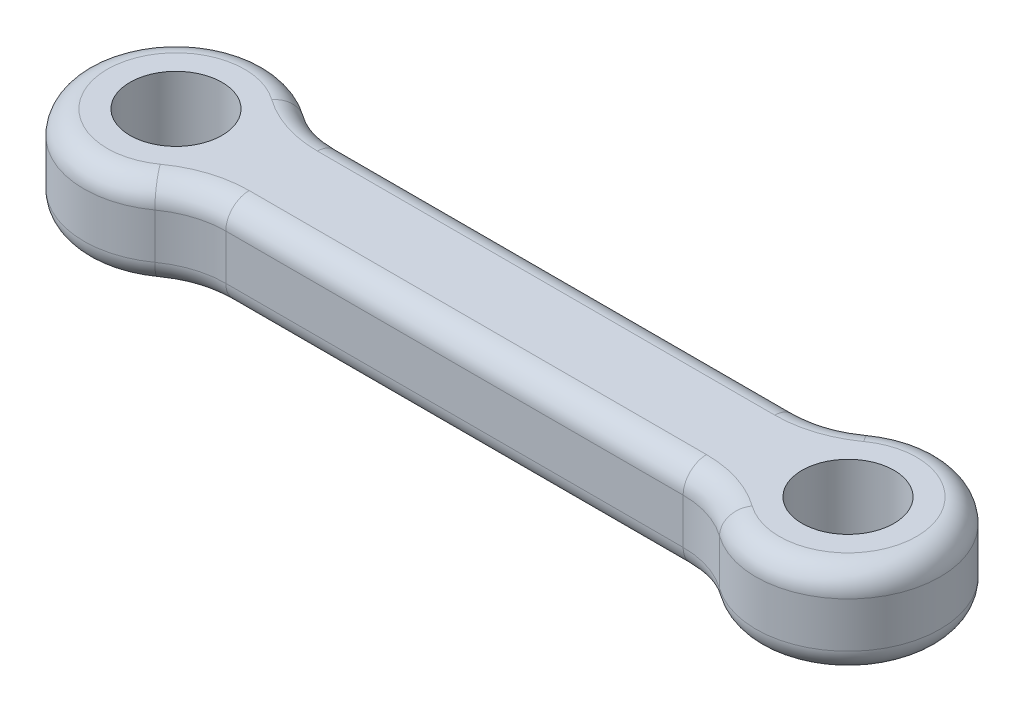
from build123d import *

# Parameters (mm, degrees)
SKETCH1_R           = 5
BOSS_EXTRUDE1_DEPTH = 10
FILLET1_R           = 2.54
SCALE1_SCALE        = 0.66


with BuildPart() as part:
    # Sketch1 → Boss-Extrude1 (new body)
    with BuildSketch(Plane(origin=(0, 0, 0), x_dir=(1, 0, 0), z_dir=(0, 1, 0))):
        with BuildLine():
            Line((-6.590776184, -6.25), (43.090776184, -6.25))
            ThreePointArc((43.090776184, -6.25), (46.152638362, -6.730283618), (48.920388092, -8.125))
            ThreePointArc((48.920388092, -8.125), (64.75, 0), (48.920388092, 8.125))
            ThreePointArc((48.920388092, 8.125), (46.152638362, 6.730283618), (43.090776184, 6.25))
            Line((43.090776184, 6.25), (-6.590776184, 6.25))
            ThreePointArc((-6.590776184, 6.25), (-9.652638362, 6.730283618), (-12.420388092, 8.125))
            ThreePointArc((-12.420388092, 8.125), (-28.25, 0), (-12.420388092, -8.125))
            ThreePointArc((-12.420388092, -8.125), (-9.652638362, -6.730283618), (-6.590776184, -6.25))
        make_face()
        with Locations((-18.25, 0)):
            Circle(SKETCH1_R, mode=Mode.SUBTRACT)
        with Locations((54.75, 0)):
            Circle(SKETCH1_R, mode=Mode.SUBTRACT)
    extrude(amount=BOSS_EXTRUDE1_DEPTH)

    # Fillet1
    fillet1_edges = [part.edges().sort_by_distance(p)[0] for p in [
        (-9.652638362, 10, 6.730283618),
        (-28.25, 0, 0),
        (-9.652638362, 0, -6.730283618),
        (18.25, 10, 6.25),
        (46.152638362, 10, 6.730283618),
        (64.75, 10, 0),
        (46.152638362, 10, -6.730283618),
        (18.25, 10, -6.25),
        (-9.652638362, 10, -6.730283618),
        (-28.25, 10, 0),
        (18.25, 0, -6.25),
        (46.152638362, 0, -6.730283618),
        (64.75, 0, 0),
        (46.152638362, 0, 6.730283618),
        (18.25, 0, 6.25),
        (-9.652638362, 0, 6.730283618),
    ]]
    fillet(fillet1_edges, radius=FILLET1_R)


with BuildPart() as part_1:
    # Scale1: scaled about (18.25, 5, 0)
    add(part.part.scale(SCALE1_SCALE).moved(Location((6.205, 1.7, 0))))


solid = part_1.part
